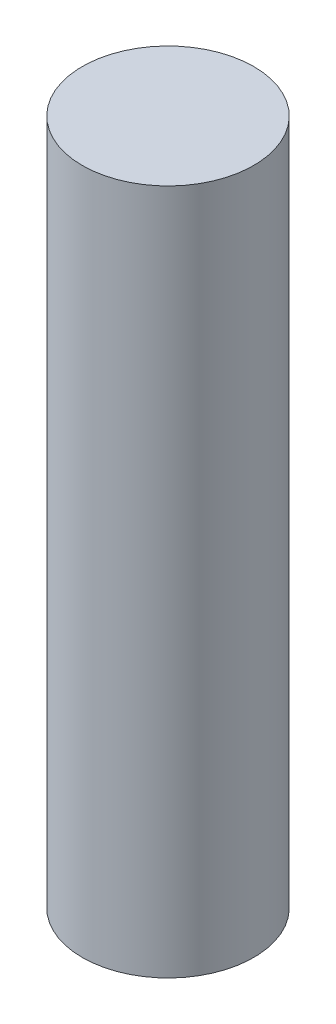
from build123d import *

# Parameters (mm, degrees)
SKETCH1_R           = 0.79375
BOSS_EXTRUDE1_DEPTH = 6.35


with BuildPart() as part:
    # Sketch1 → Boss-Extrude1 (new body)
    with BuildSketch(Plane(origin=(0, 0, 0), x_dir=(1, 0, 0), z_dir=(0, 1, 0))):
        Circle(SKETCH1_R)
    extrude(amount=BOSS_EXTRUDE1_DEPTH)


solid = part.part
